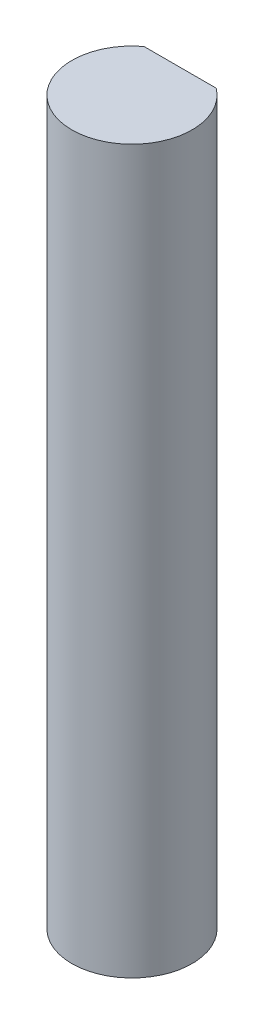
from build123d import *

# Parameters (mm, degrees)
BOSS_EXTRUDE1_DEPTH = 38.1


with BuildPart() as part:
    # Sketch1 → Boss-Extrude1 (new body)
    with BuildSketch(Plane(origin=(0, 0, 0), x_dir=(1, 0, 0), z_dir=(0, 1, 0))):
        with BuildLine():
            Line((-1.905, 2.54), (1.905, 2.54))
            ThreePointArc((1.905, 2.54), (0, -3.175), (-1.905, 2.54))
        make_face()
    extrude(amount=BOSS_EXTRUDE1_DEPTH)


solid = part.part
